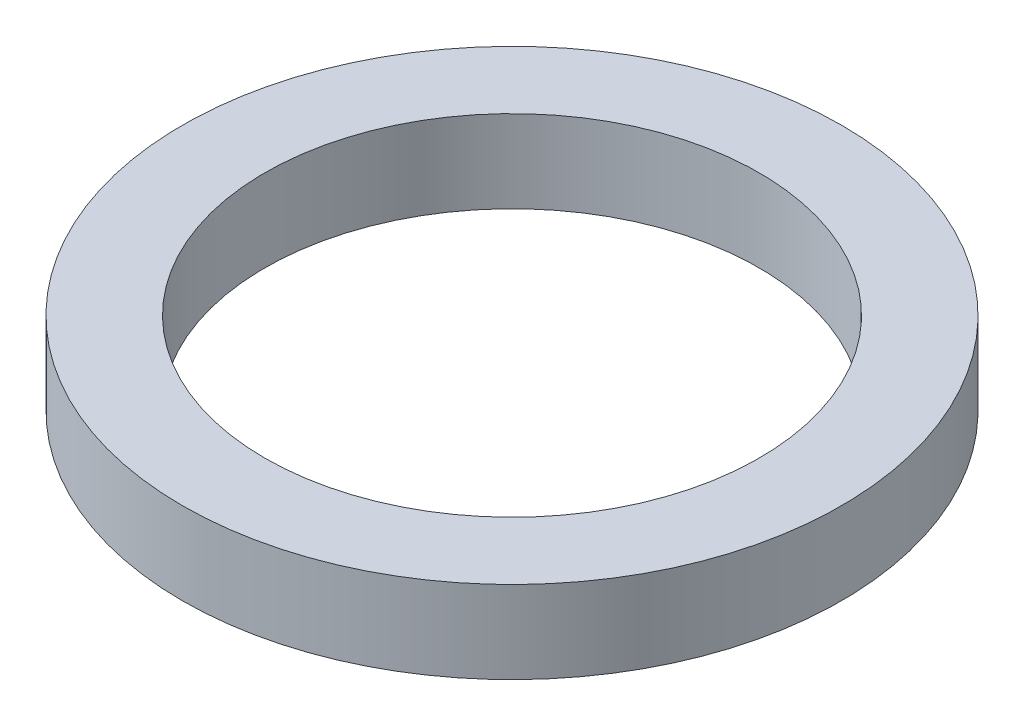
from build123d import *

# Parameters (mm, degrees)
SKETCH1_W = 1
SKETCH1_H = 1


with BuildPart() as part:
    # Sketch1 → Revolve1 (revolve)
    with BuildSketch(Plane(origin=(0, 0, 0), x_dir=(0, 0, -1), z_dir=(1, 0, 0))):
        with Locations((3.5, 0)):
            Rectangle(SKETCH1_W, SKETCH1_H)
    revolve(axis=Axis((0, 10.072992701, 0), (0, -1, 0)))


solid = part.part
